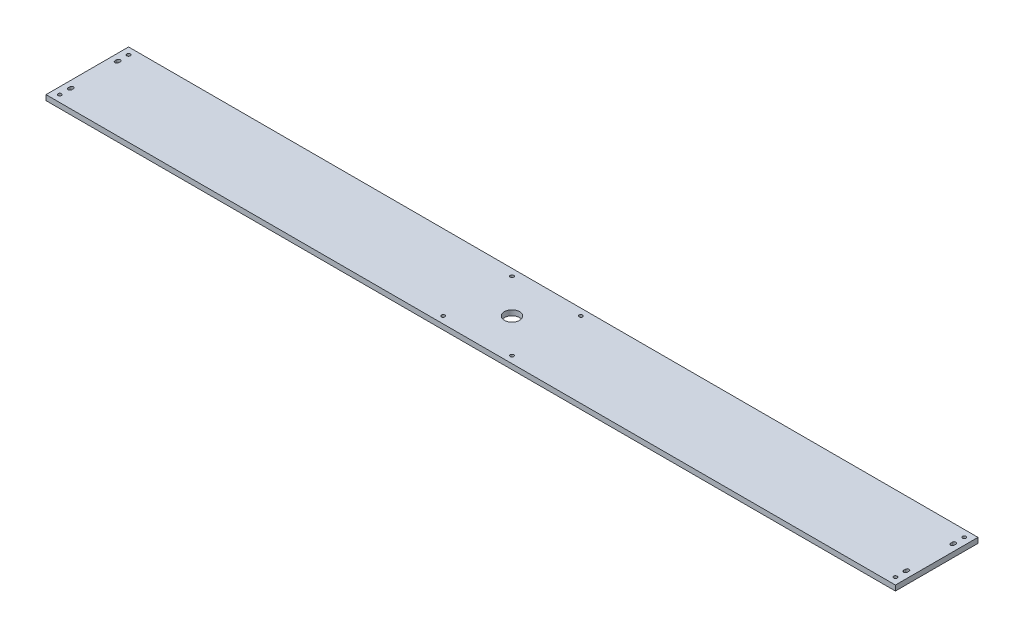
from build123d import *

# Parameters (mm, degrees)
SKETCH1_W           = 1567.434
SKETCH1_H           = 152.4
BOSS_EXTRUDE1_DEPTH = 9.652
SKETCH2_R           = 3.175
SKETCH2_R_2         = 13.97
CUT_EXTRUDE2_DEPTH  = 10.652


with BuildPart() as part:
    # Sketch1 → Boss-Extrude1 (new body)
    with BuildSketch(Plane(origin=(0, 0, 0), x_dir=(1, 0, 0), z_dir=(0, 1, 0))):
        with Locations((0.575131409, 106.973938621)):
            Rectangle(SKETCH1_W, SKETCH1_H)
    extrude(amount=BOSS_EXTRUDE1_DEPTH)

    # Sketch2 → Cut-Extrude2 (cut, through all)
    with BuildSketch(Plane(origin=(0, 9.652, 0), x_dir=(1, 0, 0), z_dir=(0, 1, 0))):
        with Locations((-770.441868591, 170.473938621)):
            Circle(SKETCH2_R)
        with Locations((-770.441868591, 43.473938621)):
            Circle(SKETCH2_R)
        with Locations((771.592131409, 43.473938621)):
            Circle(SKETCH2_R)
        with Locations((771.592131409, 170.473938621)):
            Circle(SKETCH2_R)
        with Locations((0.575131409, 106.973938621)):
            Circle(SKETCH2_R_2)
        with Locations((-62.924868591, 170.473938621)):
            Circle(SKETCH2_R)
        with Locations((-62.924868591, 43.473938621)):
            Circle(SKETCH2_R)
        with Locations((64.075131409, 43.473938621)):
            Circle(SKETCH2_R)
        with Locations((64.075131409, 170.473938621)):
            Circle(SKETCH2_R)
        with BuildLine():
            Line((-773.743868591, 148.502938621), (-773.743868591, 151.804938621))
            ThreePointArc((-773.743868591, 151.804938621), (-770.441868591, 155.106938621), (-767.139868591, 151.804938621))
            Line((-767.139868591, 151.804938621), (-767.139868591, 148.502938621))
            ThreePointArc((-767.139868591, 148.502938621), (-770.441868591, 145.200938621), (-773.743868591, 148.502938621))
        make_face()
        with BuildLine():
            Line((-773.743868591, 65.444938621), (-773.743868591, 62.142938621))
            ThreePointArc((-773.743868591, 62.142938621), (-770.441868591, 58.840938621), (-767.139868591, 62.142938621))
            Line((-767.139868591, 62.142938621), (-767.139868591, 65.444938621))
            ThreePointArc((-767.139868591, 65.444938621), (-770.441868591, 68.746938621), (-773.743868591, 65.444938621))
        make_face()
        with BuildLine():
            Line((774.894131409, 65.444938621), (774.894131409, 62.142938621))
            ThreePointArc((774.894131409, 62.142938621), (771.592131409, 58.840938621), (768.290131409, 62.142938621))
            Line((768.290131409, 62.142938621), (768.290131409, 65.444938621))
            ThreePointArc((768.290131409, 65.444938621), (771.592131409, 68.746938621), (774.894131409, 65.444938621))
        make_face()
        with BuildLine():
            Line((774.894131409, 148.502938621), (774.894131409, 151.804938621))
            ThreePointArc((774.894131409, 151.804938621), (771.592131409, 155.106938621), (768.290131409, 151.804938621))
            Line((768.290131409, 151.804938621), (768.290131409, 148.502938621))
            ThreePointArc((768.290131409, 148.502938621), (771.592131409, 145.200938621), (774.894131409, 148.502938621))
        make_face()
    extrude(amount=-CUT_EXTRUDE2_DEPTH, mode=Mode.SUBTRACT)


solid = part.part
